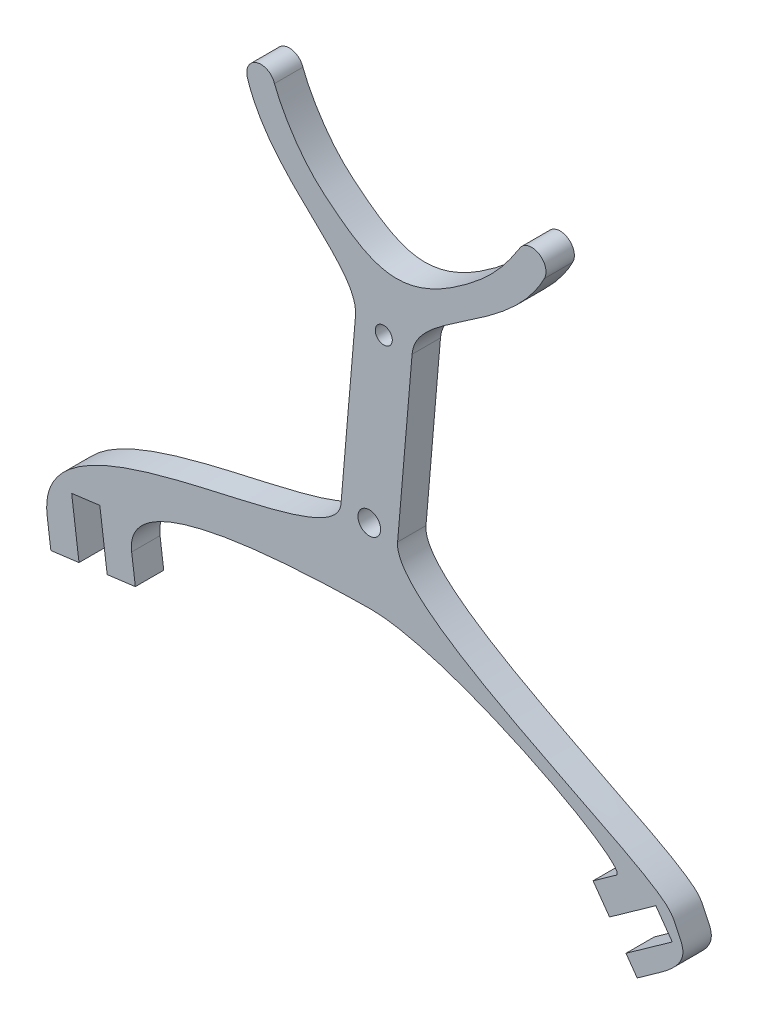
from build123d import *

# Parameters (mm, degrees)
CROQUIS2_R              = 0.1
SALIENTE_EXTRUIR1_DEPTH = 0.25
CORTAR_EXTRUIR1_REACH   = 2.25
CROQUIS3_R              = 0.075


with BuildPart() as part:
    # Croquis2 → Saliente-Extruir1 (new body)
    with BuildSketch(Plane.XY):
        with BuildLine():
            Line((-0.269598267, 0.022789063), (-0.142105821, 1.517361134))
            add(Edge.make_bspline(
                [(-0.142105821, 1.517361134), (-0.109838872, 1.89562104), (-0.885940975, 2.203998579), (-1.093422206, 2.857380392)],
                knots=[0, 0, 0, 0, 1, 1, 1, 1], degree=3))
            ThreePointArc((-1.093422206, 2.857380392), (-1.012116817, 3.014349923), (-0.855147286, 2.933044534))
            add(Edge.make_bspline(
                [(-0.855147286, 2.933044534), (-0.802855117, 2.791522862), (-0.626812715, 2.478271421), (-0.035560561, 1.991764327), (0.301694252, 1.837503211), (1.044165071, 2.405999525), (1.189353221, 2.580037978), (1.298605199, 2.749321595)],
                knots=[0, 0, 0, 0, 0.244258263, 0.330799973, 0.806015197, 0.87887539, 1, 1, 1, 1], degree=3))
            ThreePointArc((1.298605199, 2.749321595), (1.467077873, 2.802865578), (1.520621856, 2.634392904))
            add(Edge.make_bspline(
                [(0.35608487, 1.474863652), (0.388351819, 1.853123558), (1.20547196, 2.025593431), (1.520621856, 2.634392904)],
                knots=[0, 0, 0, 0, 1, 1, 1, 1], degree=3))
            Line((0.35608487, 1.474863652), (0.228592423, -0.01970842))
            add(Edge.make_bspline(
                [(0.228592423, -0.01970842), (0.186017725, -0.518804304), (2.575198102, -1.415220642), (2.703175685, -1.813334927), (2.829784292, -1.939232669), (2.541637207, -2.144125176)],
                knots=[0, 0, 0, 0, 0.598179598, 0.698179598, 1, 1, 1, 1], degree=3))
            Line((2.541637207, -2.144125176), (2.33789434, -2.289000447))
            Line((2.33789434, -2.289000447), (2.238900912, -2.149782727))
            Line((2.238900912, -2.149782727), (2.646386646, -1.860032185))
            Line((2.646386646, -1.860032185), (2.501511376, -1.656289318))
            Line((2.501511376, -1.656289318), (2.094025641, -1.946039859))
            Line((2.094025641, -1.946039859), (1.94915037, -1.742296992))
            Line((1.94915037, -1.742296992), (2.152893238, -1.597421721))
            add(Edge.make_bspline(
                [(0, -0.6492922), (0.733736911, -0.658123462), (2.29312136, -1.497709828), (2.152893238, -1.597421721)],
                knots=[0, 0, 0, 0, 1, 1, 1, 1], degree=3))
            add(Edge.make_bspline(
                [(-2.112304641, -1.266657747), (-2.188936025, -0.677872613), (0, -0.6492922)],
                knots=[0, 0, 0, 1, 1, 1], degree=2))
            Line((-2.112304641, -1.266657747), (-2.080038852, -1.514566841))
            Line((-2.080038852, -1.514566841), (-2.327947946, -1.54683263))
            Line((-2.327947946, -1.54683263), (-2.392479524, -1.051014442))
            Line((-2.392479524, -1.051014442), (-2.640388618, -1.083280231))
            Line((-2.640388618, -1.083280231), (-2.57585704, -1.579098419))
            Line((-2.57585704, -1.579098419), (-2.823766134, -1.611364208))
            Line((-2.823766134, -1.611364208), (-2.856031923, -1.363455114))
            add(Edge.make_bspline(
                [(-0.269598267, 0.022789063), (-0.313593623, -0.492960939), (-2.983037055, -0.387631246), (-2.856031923, -1.363455114)],
                knots=[0, 0, 0, 0, 1, 1, 1, 1], degree=3))
        make_face()
        with Locations((-0.020502922, 0.001540322)):
            Circle(CROQUIS2_R, mode=Mode.SUBTRACT)
    extrude(amount=SALIENTE_EXTRUIR1_DEPTH)

    # Croquis3 → Cortar-Extruir1 (cut, up to next)
    with BuildSketch(Plane.XY.offset(0.25), mode=Mode.PRIVATE) as cortar_extruir1_sk1:
        with Locations((0.106995218, 1.496179141)):
            Circle(CROQUIS3_R)
    cortar_extruir1_tool1 = extrude(cortar_extruir1_sk1.sketch, amount=-CORTAR_EXTRUIR1_REACH, mode=Mode.PRIVATE) & part.part
    add(cortar_extruir1_tool1.solids().sort_by_distance((0.106995, 1.496179, 0.25))[0], mode=Mode.SUBTRACT)


solid = part.part
